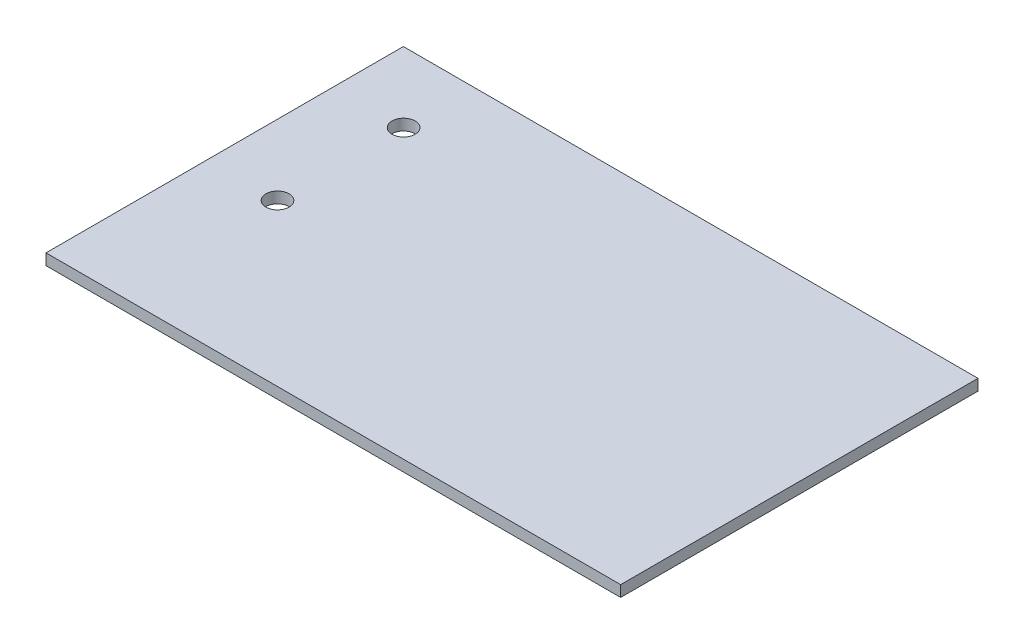
from build123d import *

# Parameters (mm, degrees)
SKETCH1_W           = 82
SKETCH1_H           = 50.991578634
BOSS_EXTRUDE1_DEPTH = 1.5875
SKETCH2_R           = 1.65
CUT_EXTRUDE1_DEPTH  = 10


with BuildPart() as part:
    # Sketch1 → Boss-Extrude1 (new body)
    with BuildSketch(Plane(origin=(0, 0, 0), x_dir=(1, 0, 0), z_dir=(0, 1, 0))):
        with Locations((41, 25.495789317)):
            Rectangle(SKETCH1_W, SKETCH1_H)
    extrude(amount=BOSS_EXTRUDE1_DEPTH)

    # Sketch2 → Cut-Extrude1 (cut)
    with BuildSketch(Plane(origin=(0, 1.5875, 0), x_dir=(1, 0, 0), z_dir=(0, 1, 0))):
        with Locations((10.04, 40.991578634)):
            Circle(SKETCH2_R)
        with Locations((10.04, 22.991578634)):
            Circle(SKETCH2_R)
    extrude(amount=-CUT_EXTRUDE1_DEPTH, mode=Mode.SUBTRACT)


solid = part.part
